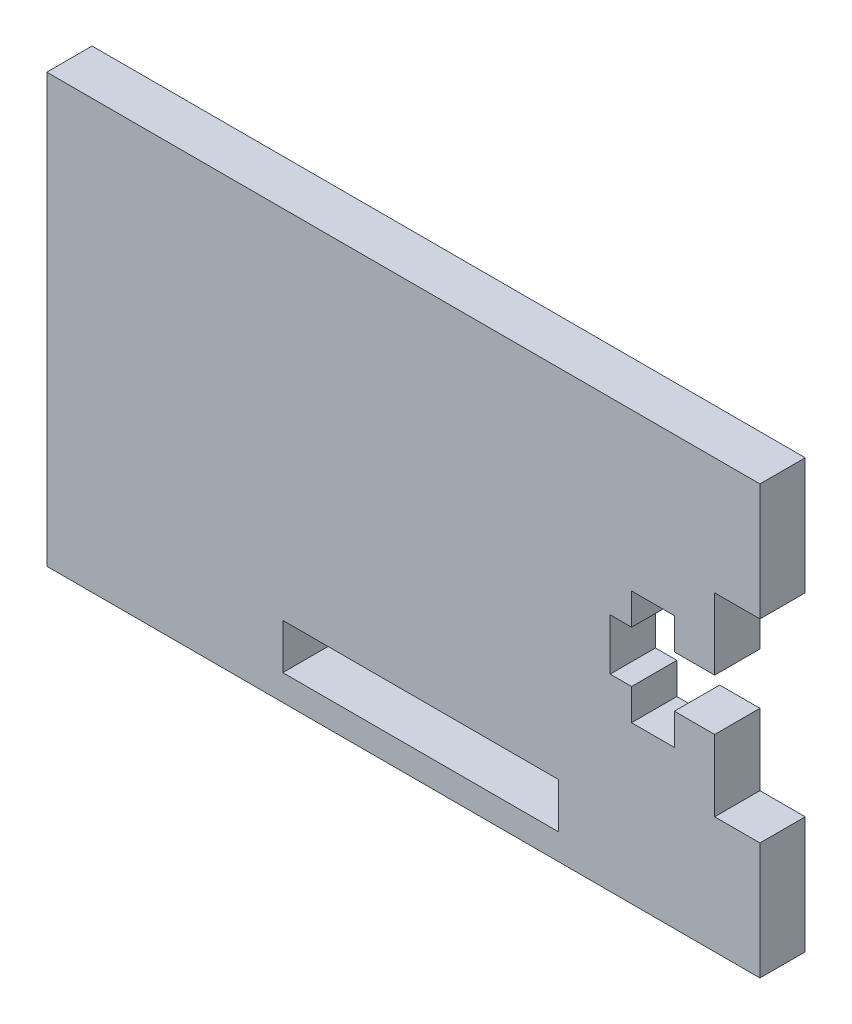
from build123d import *

# Parameters (mm, degrees)
SKETCH1_W           = 19.338503776
SKETCH1_H           = 3.175
BOSS_EXTRUDE1_DEPTH = 3.175


with BuildPart() as part:
    # Sketch1 → Boss-Extrude1 (new body)
    with BuildSketch(Plane.XY):
        Polygon((-96.911258203, 47.780766243), (-46.911258203, 47.780766243), (-46.911258203, 39.580766243), (-50.086258203, 39.580766243), (-50.086258203, 34.580766243), (-52.911258203, 34.580766243), (-52.911258203, 36.780766243), (-55.911258203, 36.780766243), (-55.911258203, 34.580766243), (-57.411258203, 34.580766243), (-57.411258203, 30.980766243), (-55.911258203, 30.980766243), (-55.911258203, 28.780766243), (-52.911258203, 28.780766243), (-52.911258203, 30.980766243), (-50.086258203, 30.980766243), (-50.086258203, 25.980766243), (-46.911258203, 25.980766243), (-46.911258203, 17.780766243), (-96.911258203, 17.780766243), align=None)
        with Locations((-70.694345596, 21.182701237)):
            Rectangle(SKETCH1_W, SKETCH1_H, mode=Mode.SUBTRACT)
    extrude(amount=BOSS_EXTRUDE1_DEPTH)


solid = part.part
